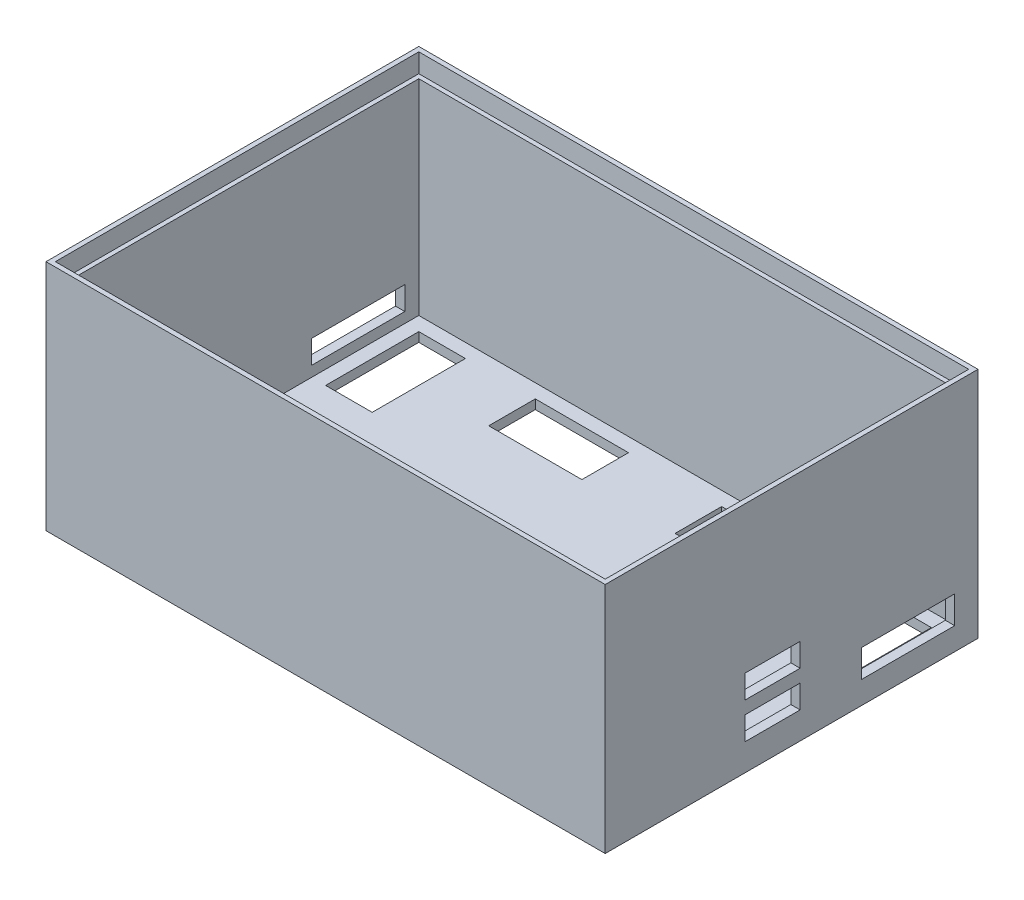
from build123d import *

# Parameters (mm, degrees)
SKETCH1_W           = 120
SKETCH1_H           = 80
BOSS_EXTRUDE1_DEPTH = 50
SHELL1_T            = -2
SKETCH3_R           = 2.5
SKETCH3_W           = 37.6
SKETCH3_H           = 19
SKETCH3_W_2         = 10
SKETCH3_H_2         = 20
SKETCH3_W_3         = 20
SKETCH3_H_3         = 10
CUT_EXTRUDE1_DEPTH  = 2
SKETCH4_R           = 3.5
SKETCH4_W           = 20
SKETCH4_H           = 5
CUT_EXTRUDE2_DEPTH  = 2
SKETCH5_W           = 118
SKETCH5_H           = 78
CUT_EXTRUDE3_DEPTH  = 4
CUT_EXTRUDE3_TAPER  = 1
SKETCH6_W           = 11.841510552
SKETCH6_H           = 5
SKETCH6_W_2         = 20
SKETCH6_H_2         = 5.927680675
CUT_EXTRUDE4_DEPTH  = 4


with BuildPart() as part:
    # Sketch1 → Boss-Extrude1 (new body)
    with BuildSketch(Plane(origin=(0, 0, 0), x_dir=(1, 0, 0), z_dir=(0, 1, 0))):
        Rectangle(SKETCH1_W, SKETCH1_H)
    extrude(amount=BOSS_EXTRUDE1_DEPTH)

    # Shell1
    shell1_openings = [part.faces().sort_by_distance(p)[0] for p in [
        (0, 50, 0),
    ]]
    offset(amount=SHELL1_T, openings=shell1_openings, kind=Kind.INTERSECTION)

    # Sketch3 → Cut-Extrude1 (cut)
    with BuildSketch(Plane.XZ):
        with Locations((-50, 31.648007145)):
            Circle(SKETCH3_R)
        with Locations((-50, 23.107977616)):
            Circle(SKETCH3_R)
        with Locations((0, 23.513536142)):
            Rectangle(SKETCH3_W, SKETCH3_H)
        with Locations((-50, -25)):
            Rectangle(SKETCH3_W_2, SKETCH3_H_2)
        with Locations((20, -30)):
            Rectangle(SKETCH3_W_3, SKETCH3_H_3)
        with Locations((-20, -30)):
            Rectangle(SKETCH3_W_3, SKETCH3_H_3)
        with Locations((50, -25)):
            Rectangle(SKETCH3_W_2, SKETCH3_H_2)
    extrude(amount=-CUT_EXTRUDE1_DEPTH, mode=Mode.SUBTRACT)

    # Sketch4 → Cut-Extrude2 (cut)
    with BuildSketch(Plane.ZY.offset(60)):
        with Locations((5, 10)):
            Circle(SKETCH4_R)
        with Locations((-25, 6.740257278)):
            Rectangle(SKETCH4_W, SKETCH4_H)
    extrude(amount=-CUT_EXTRUDE2_DEPTH, mode=Mode.SUBTRACT)

    # Sketch5 → Cut-Extrude3 (cut)
    with BuildSketch(Plane(origin=(0, 50, 0), x_dir=(1, 0, 0), z_dir=(0, 1, 0))):
        Rectangle(SKETCH5_W, SKETCH5_H)
    extrude(amount=-CUT_EXTRUDE3_DEPTH, taper=CUT_EXTRUDE3_TAPER, mode=Mode.SUBTRACT)

    # Sketch6 → Cut-Extrude4 (cut)
    with BuildSketch(Plane(origin=(60, 0, 0), x_dir=(0, 0, -1), z_dir=(1, 0, 0))):
        with Locations((-4.084800513, 8.280260813)):
            Rectangle(SKETCH6_W, SKETCH6_H)
        with Locations((-4.084800513, 16.026907298)):
            Rectangle(SKETCH6_W, SKETCH6_H)
        with Locations((25, 7.816420476)):
            Rectangle(SKETCH6_W_2, SKETCH6_H_2)
    extrude(amount=-CUT_EXTRUDE4_DEPTH, mode=Mode.SUBTRACT)


solid = part.part
